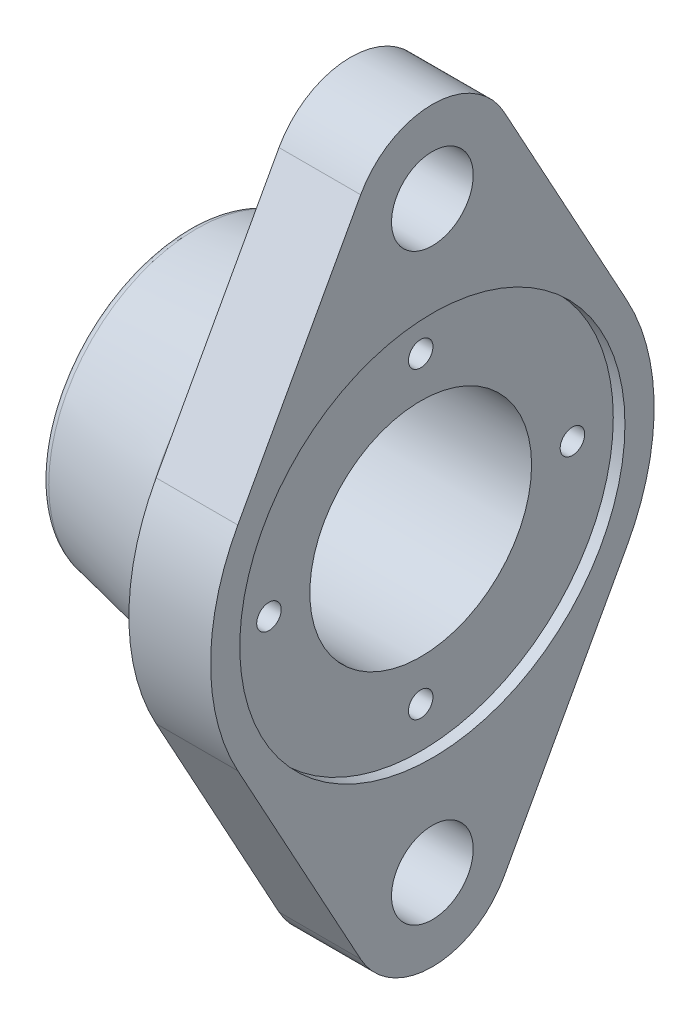
from build123d import *

# Parameters (mm, degrees)
SKICA2_R                 = 19
SKICA2_R_2               = 7
P_IDAT_VYSUNUT_M1_DEPTH  = 14
ZAOBLIT1_R               = 3
SKICA3_R                 = 33
SKICA3_R_2               = 19
ODEBRAT_VYSUNUT_M1_DEPTH = 2
ZKOSEN_1_SIZE            = 2
ZAOBLIT2_R               = 2
KRUHOV_POLE1_COUNT       = 4


with BuildPart() as part:
    # Skica1 → Rotovat1 (revolve)
    with BuildSketch(Plane.XY, mode=Mode.PRIVATE) as rotovat1_sk:
        Polygon((0, 19), (0, 32.5), (-4, 32.5), (-4, 30), (-28, 25), (-28, 22.5), (-24, 22.5), (-24, 19), align=None)
    revolve(rotovat1_sk.sketch.rotate(Axis((-37.430213862, 0, 0), (1, 0, 0)), 90), axis=Axis((-37.430213862, 0, 0), (1, 0, 0)))

    # Skica2 → Přidat vysunutím1 (add)
    with BuildSketch(Plane(origin=(0, 0, 0), x_dir=(0, 0, -1), z_dir=(1, 0, 0))):
        with BuildLine():
            Line((-33.336202543, -18.24), (-12.281758832, -56.72))
            ThreePointArc((-12.281758832, -56.72), (0, -64), (12.281758832, -56.72))
            Line((12.281758832, -56.72), (33.336202543, -18.24))
            ThreePointArc((33.336202543, -18.24), (38, 0), (33.336202543, 18.24))
            Line((33.336202543, 18.24), (12.281758832, 56.72))
            ThreePointArc((12.281758832, 56.72), (0, 64), (-12.281758832, 56.72))
            Line((-12.281758832, 56.72), (-33.336202543, 18.24))
            ThreePointArc((-33.336202543, 18.24), (-38, 0), (-33.336202543, -18.24))
        make_face()
        with Locations(Location((0, 0, 0), (0, 0, 180))):
            Circle(SKICA2_R, mode=Mode.SUBTRACT)
        with Locations((0, 50)):
            Circle(SKICA2_R_2, mode=Mode.SUBTRACT)
        with Locations((0, -50)):
            Circle(SKICA2_R_2, mode=Mode.SUBTRACT)
    extrude(amount=P_IDAT_VYSUNUT_M1_DEPTH)

    # Zaoblit1
    zaoblit1_edges = [part.edges().sort_by_distance(p)[0] for p in [
        (-4, 0, -30),
    ]]
    fillet(zaoblit1_edges, radius=ZAOBLIT1_R)

    # Skica3 → Odebrat vysunutím1 (cut)
    with BuildSketch(Plane(origin=(14, 0, 0), x_dir=(0, 0, -1), z_dir=(1, 0, 0))):
        Circle(SKICA3_R)
        with Locations(Location((0, 0, 0), (0, 0, 180))):
            Circle(SKICA3_R_2, mode=Mode.SUBTRACT)
    extrude(amount=-ODEBRAT_VYSUNUT_M1_DEPTH, mode=Mode.SUBTRACT)

    # Zkosení1
    zkosen_1_edges = [part.edges().sort_by_distance(p)[0] for p in [
        (-24, 0, -19),
    ]]
    chamfer(zkosen_1_edges, length=ZKOSEN_1_SIZE)

    # Zaoblit2
    zaoblit2_edges = [part.edges().sort_by_distance(p)[0] for p in [
        (0, 0, -32.5),
        (-28, 0, -25),
    ]]
    fillet(zaoblit2_edges, radius=ZAOBLIT2_R)

    # Skica6 → M5 závit1 (revolve, cut)
    with BuildSketch(Plane(origin=(12, 0, 26), x_dir=(0, 0, -1), z_dir=(0, 1, 0))):
        Polygon((0, 0), (0, 11.2618073), (2.1, 10), (2.1, 0), align=None)
    m5_z_vit1 = revolve(axis=Axis((18.35, 0, 26), (-1, 0, 0)), mode=Mode.SUBTRACT)

    # Kruhové pole1: M5 závit1 ×4 about axis
    kruhov_pole1_axis = Axis((0, 0, 0), (1, 0, 0))
    for i in range(1, KRUHOV_POLE1_COUNT):
        add(m5_z_vit1.rotate(kruhov_pole1_axis, i * 360 / KRUHOV_POLE1_COUNT), mode=Mode.SUBTRACT)


solid = part.part
